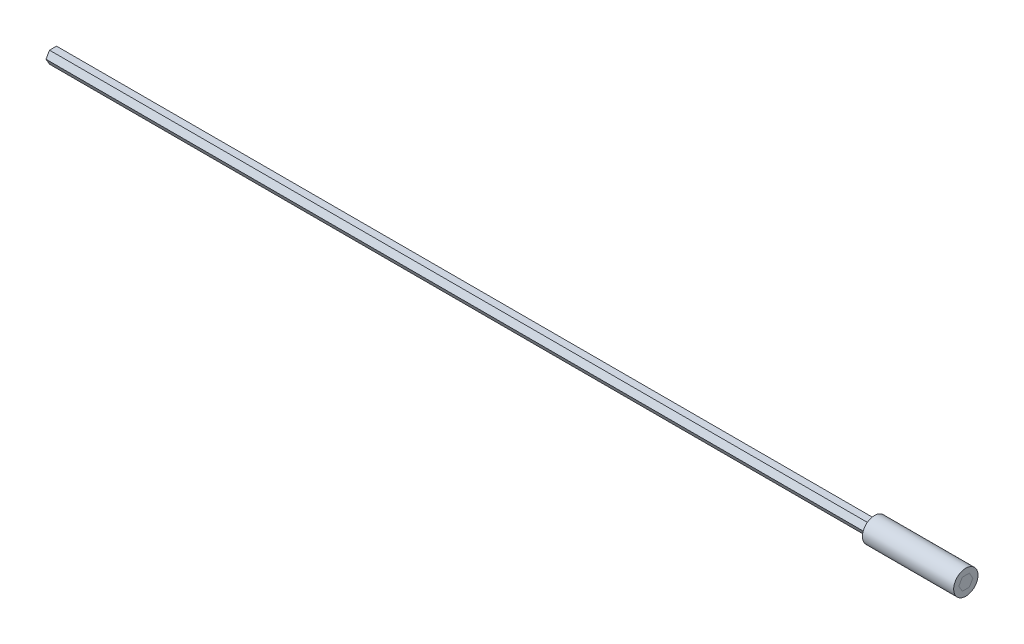
from build123d import *

# Parameters (mm, degrees)
AXLE_HEX_2MM_DEPTH  = 75
SKETCH2_R           = 2
BOSS_EXTRUDE1_DEPTH = 15


with BuildPart() as part:
    # Sketch1 → Axle-Hex-2mm (new, symmetric)
    with BuildSketch(Plane(origin=(0, 0, 0), x_dir=(0, 0, -1), z_dir=(1, 0, 0))):
        Polygon((1.154700538, 0), (0.577350269, 1), (-0.577350269, 1), (-1.154700538, 0), (-0.577350269, -1), (0.577350269, -1), align=None)
    extrude(amount=AXLE_HEX_2MM_DEPTH, both=True)


with BuildPart() as body_2:
    # Sketch2 → Boss-Extrude1 (new body)
    with BuildSketch(Plane(origin=(75, 0, 0), x_dir=(0, 0, -1), z_dir=(1, 0, 0))):
        Circle(SKETCH2_R)
        Polygon((0.577350269, -1), (1.154700538, 0), (0.577350269, 1), (-0.577350269, 1), (-1.154700538, 0), (-0.577350269, -1), align=None, mode=Mode.SUBTRACT)
    extrude(amount=-BOSS_EXTRUDE1_DEPTH)


solid = Compound([part.part, body_2.part])
